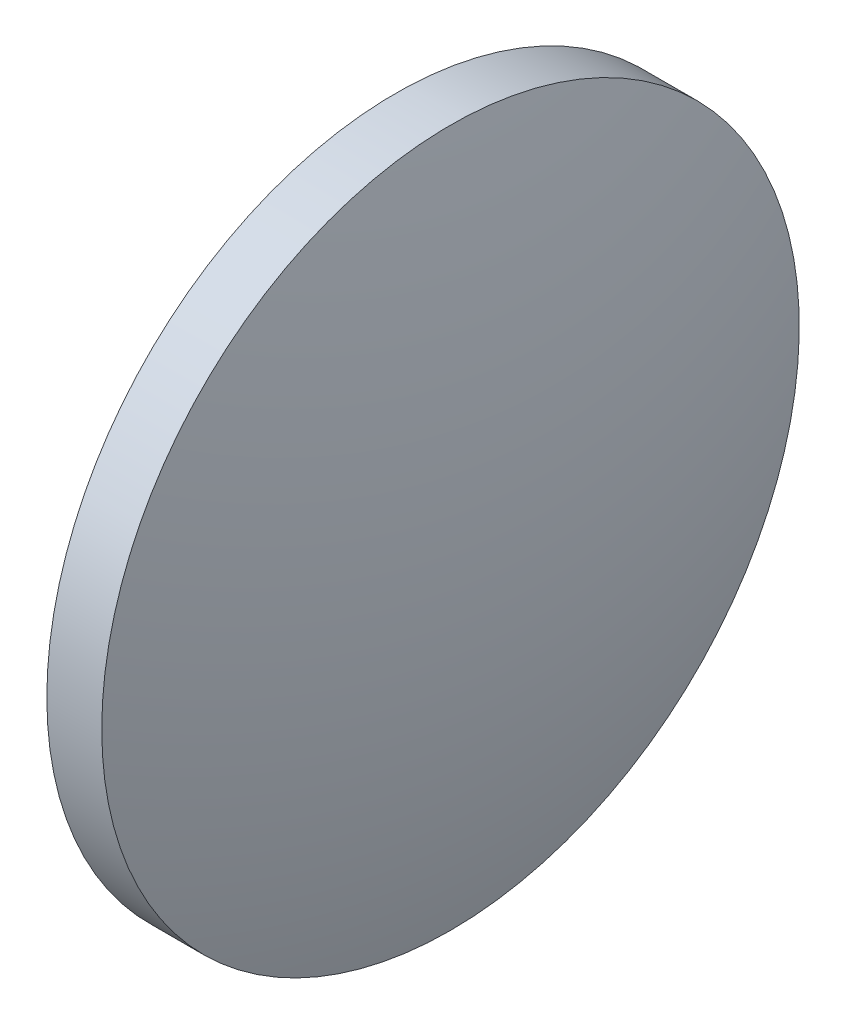
from build123d import *


with BuildPart() as part:
    # 草图1 → 旋转1 (revolve)
    with BuildSketch(Plane.XY, mode=Mode.PRIVATE) as revolve_1_sk:
        with BuildLine():
            Line((528.382850661, 102.459533873), (528.382850661, 115.159533873))
            Line((528.382850661, 115.159533873), (530.382850661, 115.159533873))
            ThreePointArc((530.382850661, 115.159533873), (531.805222128, 108.88020362), (532.282850661, 102.459533873))
            Line((532.282850661, 102.459533873), (528.382850661, 102.459533873))
        make_face()
    revolve(revolve_1_sk.sketch.rotate(Axis((522.644632625, 102.459533873, 0), (1, 0, 0)), 180), axis=Axis((522.644632625, 102.459533873, 0), (1, 0, 0)))  # turned: the seam where the file's is


solid = part.part
